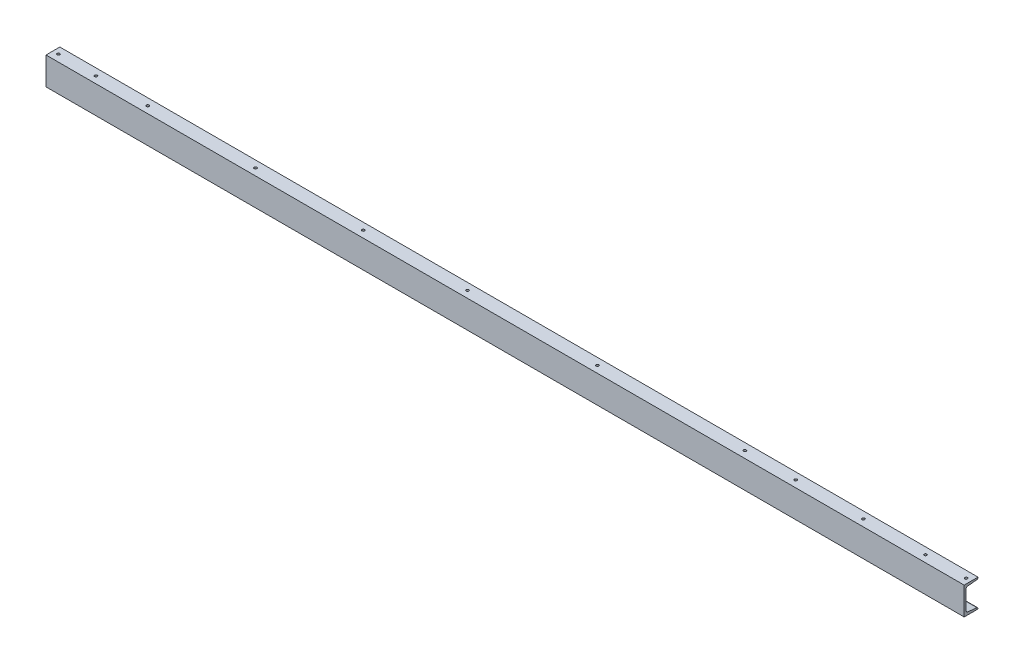
from build123d import *

# Parameters (mm, degrees)
STRUCTURAL_MEMBER1_DEPTH = 3322
SKETCH12_R               = 4.7625
CUT_EXTRUDE1_DEPTH       = 20
CUT_EXTRUDE2_DEPTH       = 40
SKETCH14_R               = 4.7625
CUT_EXTRUDE3_DEPTH       = 20
CUT_EXTRUDE4_DEPTH       = 40


with BuildPart() as part:
    # Sketch16 → Structural Member1 (new body)
    with BuildSketch(Plane(origin=(-530, -50, 0), x_dir=(0, 0, -1), z_dir=(1, 0, 0))):
        with BuildLine():
            Line((50, 100), (0, 100))
            Line((0, 100), (0, 0))
            Line((0, 0), (50, 0))
            Line((50, 0), (50, 1.629852671))
            ThreePointArc((50, 1.629852671), (48.844151715, 4.6409404), (45.970378085, 6.1052012))
            Line((45.970378085, 6.1052012), (13.063772294, 9.563824837))
            ThreePointArc((13.063772294, 9.563824837), (7.954841396, 12.166955149), (5.9, 17.52))
            Line((5.9, 17.52), (5.9, 82.48))
            ThreePointArc((5.9, 82.48), (7.954841396, 87.833044851), (13.063772294, 90.436175163))
            Line((13.063772294, 90.436175163), (45.970378085, 93.8947988))
            ThreePointArc((45.970378085, 93.8947988), (48.844151715, 95.3590596), (50, 98.370147329))
            Line((50, 98.370147329), (50, 100))
        make_face()
    extrude(amount=STRUCTURAL_MEMBER1_DEPTH)

    # Sketch12 → Cut-Extrude1 (cut)
    with BuildSketch(Plane.XZ.offset(-50)):
        with Locations(Location((-510, -25, 0), (0, 0, 270))):
            Circle(SKETCH12_R)
        with Locations(Location((-187, -25, 0), (0, 0, 270))):
            Circle(SKETCH12_R)
        with Locations(Location((202.9, -25, 0), (0, 0, 270))):
            Circle(SKETCH12_R)
        with Locations(Location((593, -25, 0), (0, 0, 270))):
            Circle(SKETCH12_R)
        with Locations(Location((970, -25, 0), (0, 0, 270))):
            Circle(SKETCH12_R)
        with Locations(Location((1440, -25, 0), (0, 0, 270))):
            Circle(SKETCH12_R)
        with Locations(Location((-374.3, -25, 0), (0, 0, 270))):
            Circle(SKETCH12_R)
        with Locations(Location((1973.8, -25, 0), (0, 0, 270))):
            Circle(SKETCH12_R)
        with Locations(Location((2157.4, -25, 0), (0, 0, 270))):
            Circle(SKETCH12_R)
        with Locations(Location((2402.5, -25, 0), (0, 0, 270))):
            Circle(SKETCH12_R)
        with Locations(Location((2626.9, -25, 0), (0, 0, 270))):
            Circle(SKETCH12_R)
        with Locations(Location((2774, -25, 0), (0, 0, 270))):
            Circle(SKETCH12_R)
    extrude(amount=CUT_EXTRUDE1_DEPTH, mode=Mode.SUBTRACT)

    # Sketch13 → Cut-Extrude2 (cut)
    with BuildSketch(Plane(origin=(0, -29.667525876, -5.9), x_dir=(-1, 0, 0), z_dir=(0, 0, -1))):
        with BuildLine():
            Line((-2786.5, 72.667525876), (-2761.5, 72.667525876))
            ThreePointArc((-2761.5, 72.667525876), (-2756.5, 67.667525876), (-2761.5, 62.667525876))
            Line((-2761.5, 62.667525876), (-2786.5, 62.667525876))
            ThreePointArc((-2786.5, 62.667525876), (-2791.5, 67.667525876), (-2786.5, 72.667525876))
        make_face()
        with BuildLine():
            Line((-2639.4, 72.667525876), (-2614.4, 72.667525876))
            ThreePointArc((-2614.4, 72.667525876), (-2609.4, 67.667525876), (-2614.4, 62.667525876))
            Line((-2614.4, 62.667525876), (-2639.4, 62.667525876))
            ThreePointArc((-2639.4, 62.667525876), (-2644.4, 67.667525876), (-2639.4, 72.667525876))
        make_face()
        with BuildLine():
            Line((-2415, 72.667525876), (-2390, 72.667525876))
            ThreePointArc((-2390, 72.667525876), (-2385, 67.667525876), (-2390, 62.667525876))
            Line((-2390, 62.667525876), (-2415, 62.667525876))
            ThreePointArc((-2415, 62.667525876), (-2420, 67.667525876), (-2415, 72.667525876))
        make_face()
        with BuildLine():
            Line((-2169.9, 72.667525876), (-2144.9, 72.667525876))
            ThreePointArc((-2144.9, 72.667525876), (-2139.9, 67.667525876), (-2144.9, 62.667525876))
            Line((-2144.9, 62.667525876), (-2169.9, 62.667525876))
            ThreePointArc((-2169.9, 62.667525876), (-2174.9, 67.667525876), (-2169.9, 72.667525876))
        make_face()
        with BuildLine():
            Line((-1986.3, 72.667525876), (-1961.3, 72.667525876))
            ThreePointArc((-1961.3, 72.667525876), (-1956.3, 67.667525876), (-1961.3, 62.667525876))
            Line((-1961.3, 62.667525876), (-1986.3, 62.667525876))
            ThreePointArc((-1986.3, 62.667525876), (-1991.3, 67.667525876), (-1986.3, 72.667525876))
        make_face()
        with BuildLine():
            Line((361.8, 72.667525876), (386.8, 72.667525876))
            ThreePointArc((386.8, 72.667525876), (391.8, 67.667525876), (386.8, 62.667525876))
            Line((386.8, 62.667525876), (361.8, 62.667525876))
            ThreePointArc((361.8, 62.667525876), (356.8, 67.667525876), (361.8, 72.667525876))
        make_face()
        with BuildLine():
            Line((-1452.5, 72.667525876), (-1427.5, 72.667525876))
            ThreePointArc((-1427.5, 72.667525876), (-1422.5, 67.667525876), (-1427.5, 62.667525876))
            Line((-1427.5, 62.667525876), (-1452.5, 62.667525876))
            ThreePointArc((-1452.5, 62.667525876), (-1457.5, 67.667525876), (-1452.5, 72.667525876))
        make_face()
        with BuildLine():
            Line((-982.5, 72.667525876), (-957.5, 72.667525876))
            ThreePointArc((-957.5, 72.667525876), (-952.5, 67.667525876), (-957.5, 62.667525876))
            Line((-957.5, 62.667525876), (-982.5, 62.667525876))
            ThreePointArc((-982.5, 62.667525876), (-987.5, 67.667525876), (-982.5, 72.667525876))
        make_face()
        with BuildLine():
            Line((-605.5, 72.667525876), (-580.5, 72.667525876))
            ThreePointArc((-580.5, 72.667525876), (-575.5, 67.667525876), (-580.5, 62.667525876))
            Line((-580.5, 62.667525876), (-605.5, 62.667525876))
            ThreePointArc((-605.5, 62.667525876), (-610.5, 67.667525876), (-605.5, 72.667525876))
        make_face()
        with BuildLine():
            Line((-215.4, 72.667525876), (-190.4, 72.667525876))
            ThreePointArc((-190.4, 72.667525876), (-185.4, 67.667525876), (-190.4, 62.667525876))
            Line((-190.4, 62.667525876), (-215.4, 62.667525876))
            ThreePointArc((-215.4, 62.667525876), (-220.4, 67.667525876), (-215.4, 72.667525876))
        make_face()
        with BuildLine():
            Line((174.5, 72.667525876), (199.5, 72.667525876))
            ThreePointArc((199.5, 72.667525876), (204.5, 67.667525876), (199.5, 62.667525876))
            Line((199.5, 62.667525876), (174.5, 62.667525876))
            ThreePointArc((174.5, 62.667525876), (169.5, 67.667525876), (174.5, 72.667525876))
        make_face()
        with BuildLine():
            Line((497.5, 72.667525876), (522.5, 72.667525876))
            ThreePointArc((522.5, 72.667525876), (527.5, 67.667525876), (522.5, 62.667525876))
            Line((522.5, 62.667525876), (497.5, 62.667525876))
            ThreePointArc((497.5, 62.667525876), (492.5, 67.667525876), (497.5, 72.667525876))
        make_face()
    extrude(amount=CUT_EXTRUDE2_DEPTH, mode=Mode.SUBTRACT)

    # Sketch14 → Cut-Extrude3 (cut)
    with BuildSketch(Plane.XZ.offset(50)):
        with Locations(Location((-5, -25, 0), (0, 0, 270))):
            Circle(SKETCH14_R)
        with Locations(Location((2295, -25, 0), (0, 0, 270))):
            Circle(SKETCH14_R)
    extrude(amount=-CUT_EXTRUDE3_DEPTH, mode=Mode.SUBTRACT)

    # Sketch15 → Cut-Extrude4 (cut)
    with BuildSketch(Plane(origin=(0, -29.667525876, -5.9), x_dir=(-1, 0, 0), z_dir=(0, 0, -1))):
        with BuildLine():
            Line((-7.5, -3.332474124), (17.5, -3.332474124))
            ThreePointArc((17.5, -3.332474124), (22.5, -8.332474124), (17.5, -13.332474124))
            Line((17.5, -13.332474124), (-7.5, -13.332474124))
            ThreePointArc((-7.5, -13.332474124), (-12.5, -8.332474124), (-7.5, -3.332474124))
        make_face()
        with BuildLine():
            Line((-2307.5, -3.332474124), (-2282.5, -3.332474124))
            ThreePointArc((-2282.5, -3.332474124), (-2277.5, -8.332474124), (-2282.5, -13.332474124))
            Line((-2282.5, -13.332474124), (-2307.5, -13.332474124))
            ThreePointArc((-2307.5, -13.332474124), (-2312.5, -8.332474124), (-2307.5, -3.332474124))
        make_face()
    extrude(amount=CUT_EXTRUDE4_DEPTH, mode=Mode.SUBTRACT)


solid = part.part
